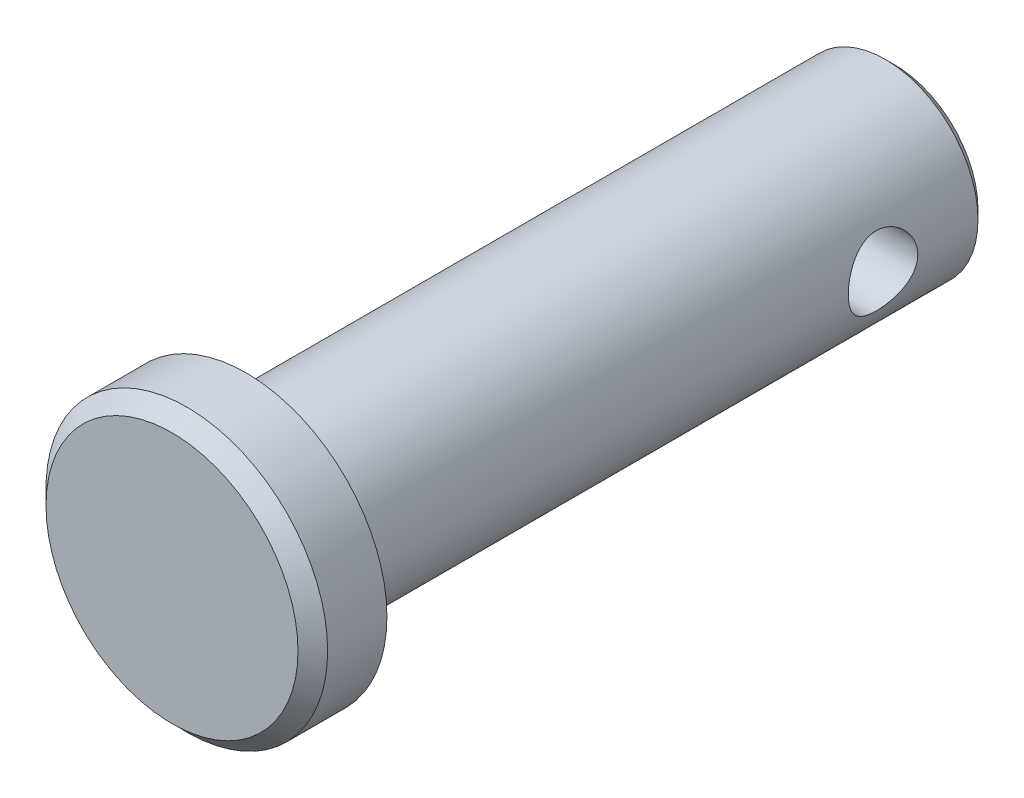
from build123d import *

# Parameters (mm, degrees)
SKETCH1_R           = 3.175
EXTRUDE1_DEPTH      = 11.1125
SKETCH2_R           = 4.826
EXTRUDE2_DEPTH      = 2.54
CHAMFER1_SIZE       = 0.508
SKETCH3_R           = 1.190625
EXTRUDE3_DEPTH      = 5.826
EXTRUDE3_DEPTH_BACK = 5.826
CHAMFER2_SIZE       = 0.3175


with BuildPart() as part:
    # Sketch1 → Extrude1 (new body, symmetric)
    with BuildSketch(Plane.XY):
        Circle(SKETCH1_R)
    extrude(amount=EXTRUDE1_DEPTH, both=True)

    # Sketch2 → Extrude2 (add)
    with BuildSketch(Plane.XY.offset(11.1125)):
        Circle(SKETCH2_R)
    extrude(amount=EXTRUDE2_DEPTH)

    # Chamfer1
    chamfer1_edges = [part.edges().sort_by_distance(p)[0] for p in [
        (-4.826, 0, 13.6525),
    ]]
    chamfer(chamfer1_edges, length=CHAMFER1_SIZE)

    # Sketch3 → Extrude3 (cut, two sides)
    with BuildSketch(Plane(origin=(0, 0, 0), x_dir=(0, 0, -1), z_dir=(1, 0, 0))) as extrude3_sk:
        with Locations((7.540625, 0)):
            Circle(SKETCH3_R)
    extrude(amount=EXTRUDE3_DEPTH, mode=Mode.SUBTRACT)
    extrude(extrude3_sk.sketch, amount=-EXTRUDE3_DEPTH_BACK, mode=Mode.SUBTRACT)

    # Chamfer2
    chamfer2_edges = [part.edges().sort_by_distance(p)[0] for p in [
        (-3.175, 0, -11.1125),
    ]]
    chamfer(chamfer2_edges, length=CHAMFER2_SIZE)


solid = part.part
